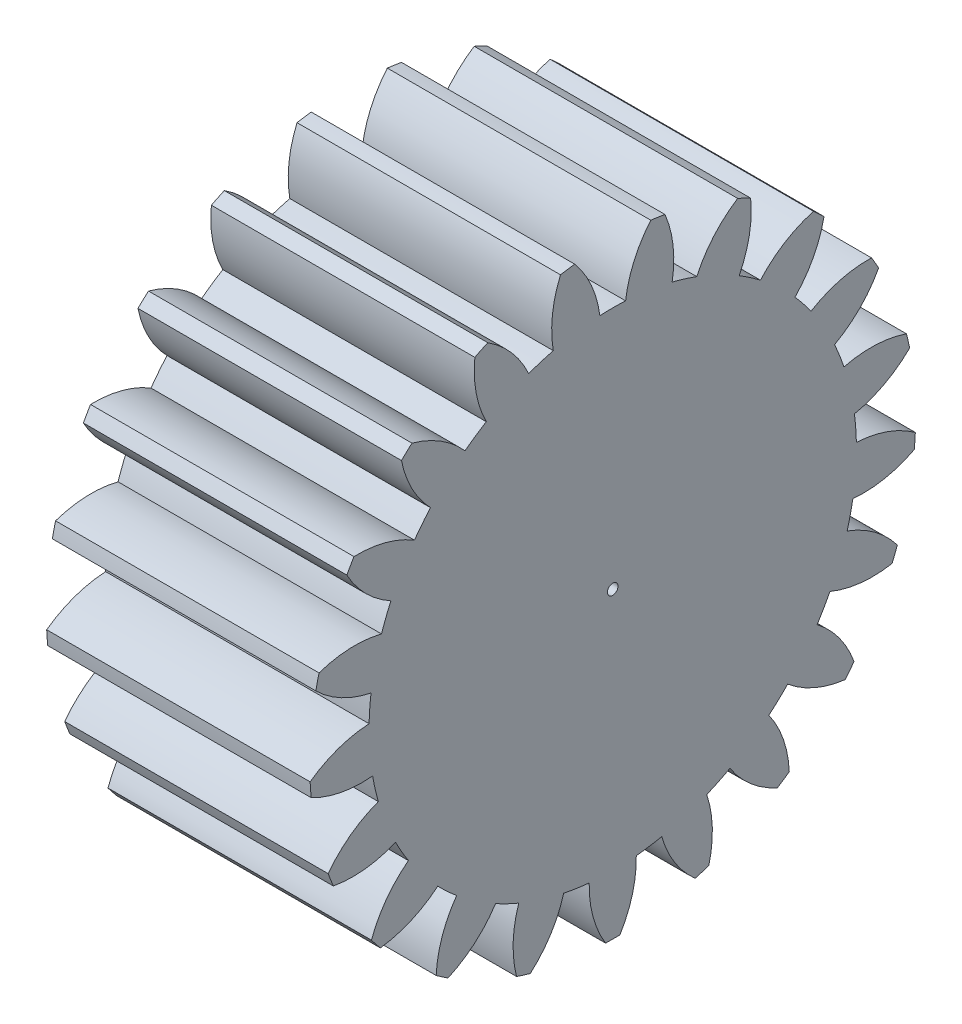
from build123d import *

# Parameters (mm, degrees)
BASPROSKE_W     = 20
BASPROSKE_H     = 23
TOOTHCUT_DEPTH  = 39.183766184
TEETHCUTS_COUNT = 21
TEETHCUTS_ANGLE = 342.857142857
BORSKE_R        = 0.4
BORE_DEPTH      = 50.0000508


with BuildPart() as part:
    # BasProSke → Base-Revolve (revolve)
    with BuildSketch(Plane(origin=(0, 0, 0), x_dir=(1, 0, 0), z_dir=(0, 1, 0)), mode=Mode.PRIVATE) as base_revolve_sk:
        with Locations((10, 11.5)):
            Rectangle(BASPROSKE_W, BASPROSKE_H)
    revolve(base_revolve_sk.sketch.rotate(Axis((-10, 0, 0), (1, 0, 0)), 180), axis=Axis((-10, 0, 0), (1, 0, 0)))

    # TooCutSke → ToothCut (cut, through all)
    with BuildSketch(Plane(origin=(0, 0, 0), x_dir=(0, 0, -1), z_dir=(1, 0, 0))):
        with BuildLine():
            ThreePointArc((0.976779145, 18.473194188), (0, 18.499), (-0.976779145, 18.473194188))
            ThreePointArc((-0.976779145, 18.473194188), (-1.625451341, 20.797249275), (-2.90802115, 22.841025768))
            ThreePointArc((-2.90802115, 22.841025768), (0, 23.0254), (2.90802115, 22.841025768))
            ThreePointArc((2.90802115, 22.841025768), (1.625451341, 20.797249275), (0.976779145, 18.473194188))
        make_face()
    toothcut = extrude(amount=TOOTHCUT_DEPTH, mode=Mode.SUBTRACT)

    # TeethCuts: ToothCut ×21 about axis
    teethcuts_axis = Axis((-10, 0, 0), (1, 0, 0))
    for i in range(1, TEETHCUTS_COUNT):
        add(toothcut.rotate(teethcuts_axis, i * TEETHCUTS_ANGLE / (TEETHCUTS_COUNT - 1)), mode=Mode.SUBTRACT)

    # BorSke → Bore (cut, symmetric)
    with BuildSketch(Plane(origin=(0, 0, 0), x_dir=(0, 0, -1), z_dir=(1, 0, 0))):
        with Locations(Location((0, 0, 0), (0, 0, 180))):
            Circle(BORSKE_R)
    extrude(amount=BORE_DEPTH, both=True, mode=Mode.SUBTRACT)


solid = part.part
